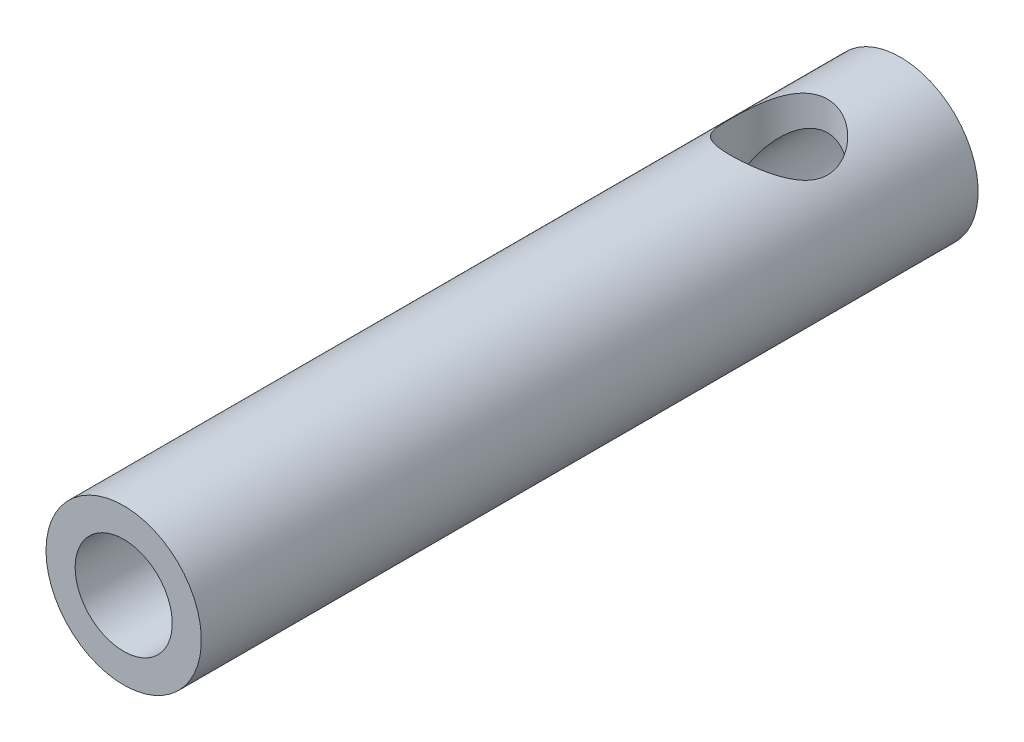
from build123d import *

# Parameters (mm, degrees)
SKIZZE1_W                       = 16
SKIZZE1_H                       = 0.6
SKIZZE2_R                       = 1
SCHNITT_LINEAR_AUSTRAGEN1_DEPTH = 2.6


with BuildPart() as part:
    # Skizze1 → Rotation1 (revolve)
    with BuildSketch(Plane(origin=(0, 0, 0), x_dir=(0, 0, -1), z_dir=(1, 0, 0))):
        with Locations((0, 1.3)):
            Rectangle(SKIZZE1_W, SKIZZE1_H)
    revolve(axis=Axis((0, 0, 0), (0, 0, 1)))

    # Skizze2 → Schnitt-Linear austragen1 (cut, through all)
    with BuildSketch(Plane(origin=(0, 0, 0), x_dir=(1, 0, 0), z_dir=(0, 1, 0))):
        with Locations((0, 5.5)):
            Circle(SKIZZE2_R)
    extrude(amount=SCHNITT_LINEAR_AUSTRAGEN1_DEPTH, mode=Mode.SUBTRACT)


solid = part.part
